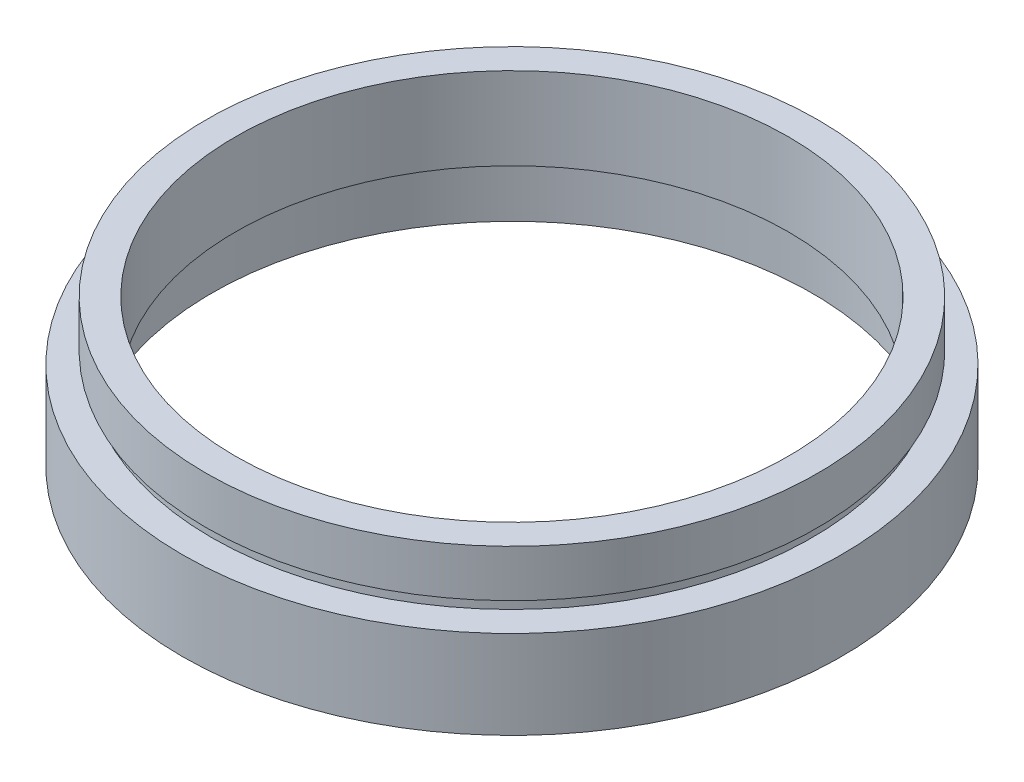
from build123d import *


with BuildPart() as part:
    # 草图1 → 旋转1 (revolve)
    with BuildSketch(Plane.XY, mode=Mode.PRIVATE) as revolve_1_sk:
        Polygon((23.5, 12.5), (26, 12.5), (26, 8.5), (25.5, 8.5), (25.5, 7.5), (28, 7.5), (28, 0), (25.5, 0), (25.5, 4.5), (26.1, 4.5), (26.1, 5.5), (23.5, 5.5), align=None)
    revolve(revolve_1_sk.sketch.rotate(Axis((0, 161.376166943, 0), (0, -1, 0)), 90), axis=Axis((0, 161.376166943, 0), (0, -1, 0)))  # turned: the seam where the file's is


solid = part.part
